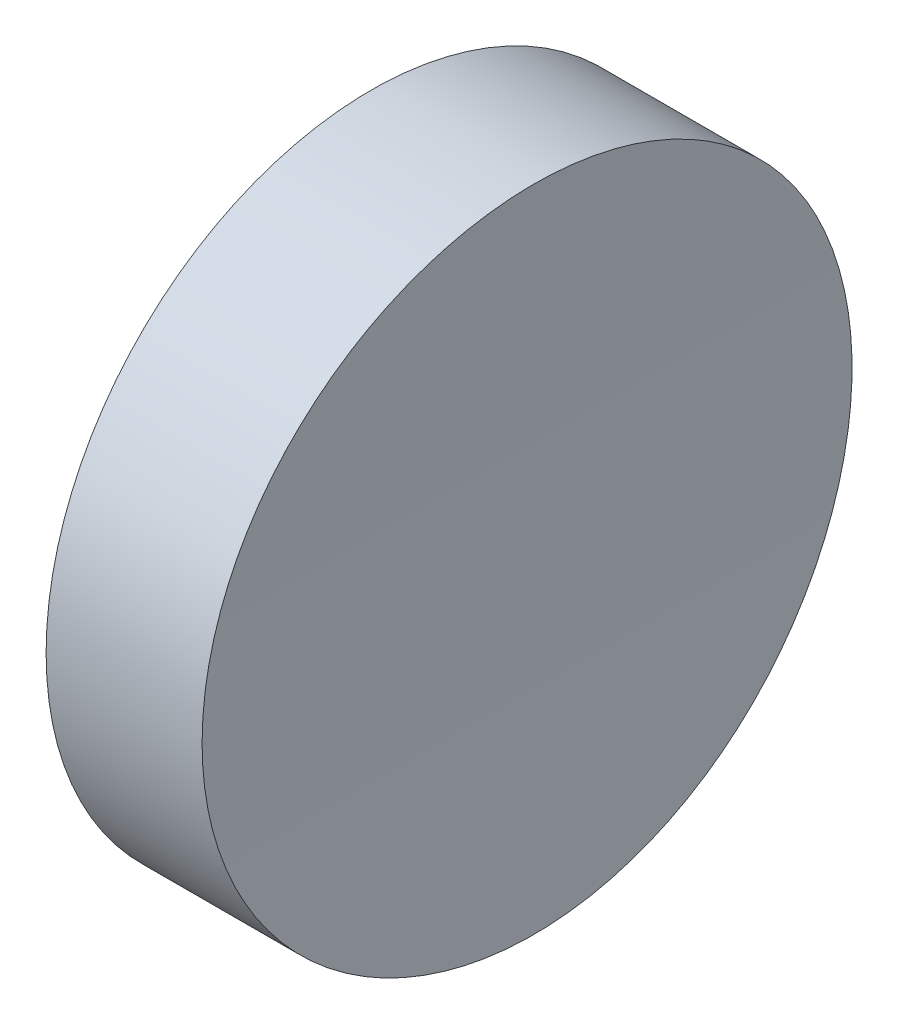
from build123d import *

# Parameters (mm, degrees)
SKETCH_1_R               = 12.5
EXTRUDE_1_DEPTH          = 10
SKETCH_2_R               = 300
CUT_EXTRUDE_1_DEPTH      = 13.5
CUT_EXTRUDE_1_DEPTH_BACK = 13.5


with BuildPart() as part:
    # 草图1 → 凸台-拉伸1 (new body)
    with BuildSketch(Plane(origin=(0, 0, 0), x_dir=(0, 0, -1), z_dir=(1, 0, 0))):
        Circle(SKETCH_1_R)
    extrude(amount=EXTRUDE_1_DEPTH)

    # 草图2 → 切除-拉伸1 (cut, two sides)
    with BuildSketch(Plane.XY) as cut_extrude_1_sk:
        with Locations((306, 0)):
            Circle(SKETCH_2_R)
    extrude(amount=CUT_EXTRUDE_1_DEPTH, mode=Mode.SUBTRACT)
    extrude(cut_extrude_1_sk.sketch, amount=-CUT_EXTRUDE_1_DEPTH_BACK, mode=Mode.SUBTRACT)


solid = part.part
